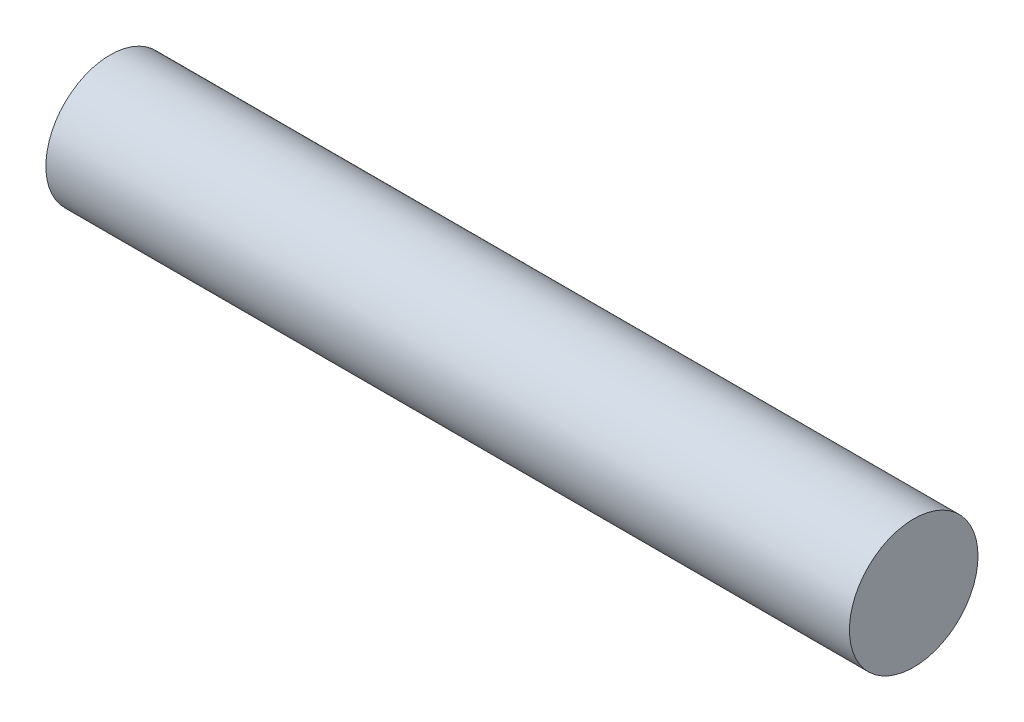
from build123d import *

# Parameters (mm, degrees)
SKETCH1_R           = 12.7
BOSS_EXTRUDE1_DEPTH = 158.75


with BuildPart() as part:
    # Sketch1 → Boss-Extrude1 (new body)
    with BuildSketch(Plane(origin=(0, 0, 0), x_dir=(0, 0, -1), z_dir=(1, 0, 0))):
        Circle(SKETCH1_R)
    extrude(amount=BOSS_EXTRUDE1_DEPTH)


solid = part.part
